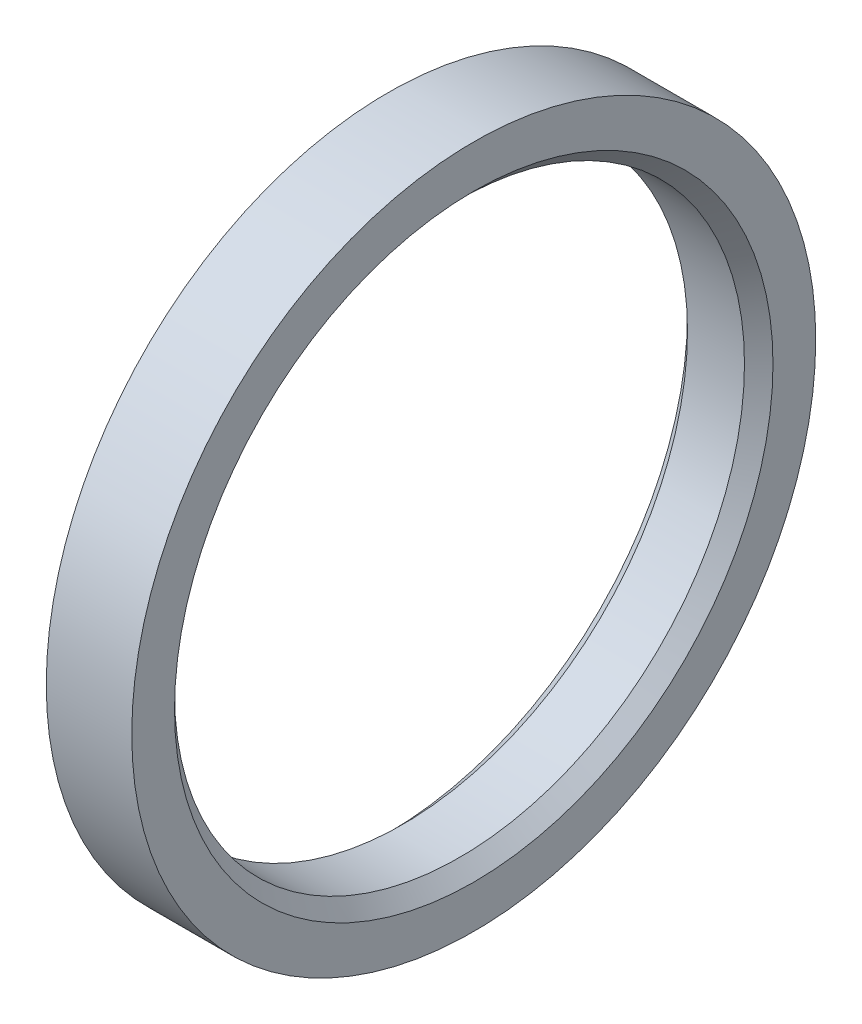
from build123d import *

# Parameters (mm, degrees)
SKETCH_1_W     = 3
SKETCH_1_H     = 2
CHAMFER_1_SIZE = 0.5


with BuildPart() as part:
    # Эскиз1 → Повернуть1 (revolve)
    with BuildSketch(Plane.XY):
        with Locations((1.5, 11)):
            Rectangle(SKETCH_1_W, SKETCH_1_H)
    revolve(axis=Axis((0, 0, 0), (-1, 0, 0)))

    # Фаска1
    chamfer_1_edges = [part.edges().sort_by_distance(p)[0] for p in [
        (0, -10, 0),
        (3, -10, 0),
    ]]
    chamfer(chamfer_1_edges, length=CHAMFER_1_SIZE)


solid = part.part
